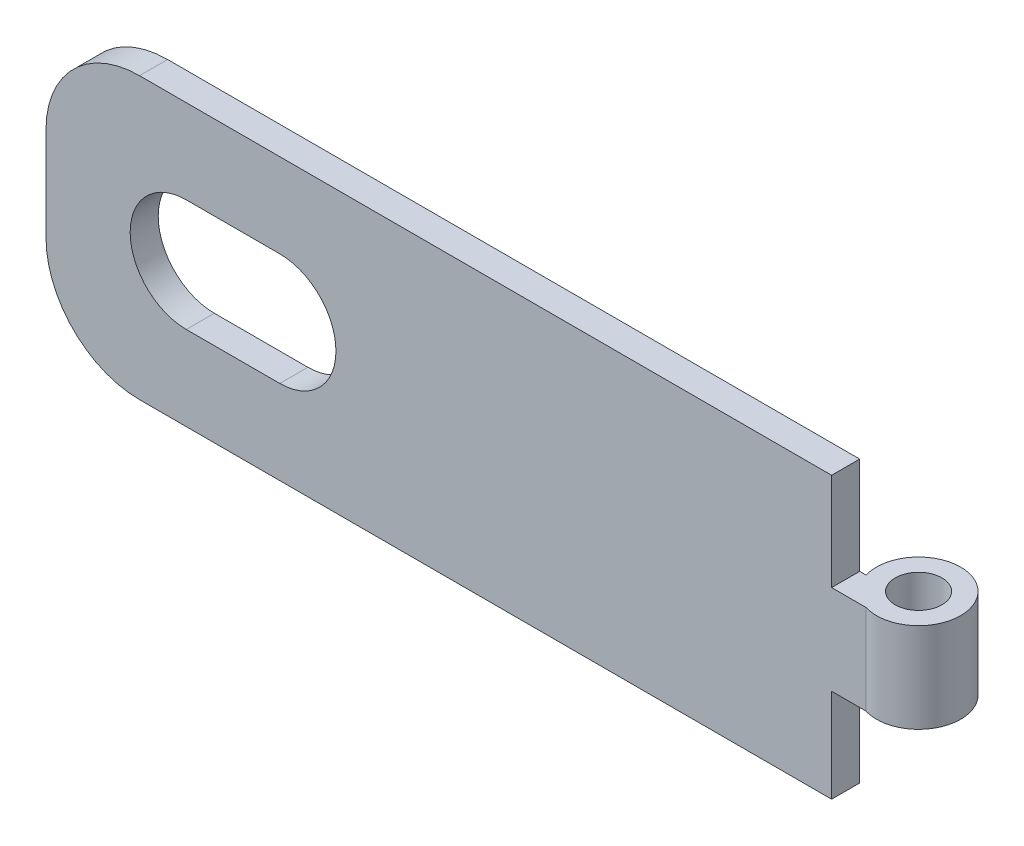
from build123d import *

# Parameters (mm, degrees)
SKETCH_1_W               = 88
SKETCH_1_H               = 3
EXTRUDE_1_DEPTH          = 30
SKETCH_2_R               = 4.5
EXTRUDE_1_2_DEPTH        = 30
SKETCH_3_R               = 2.5
CUT_EXTRUDE_1_DEPTH      = 31
SKETCH_4_W               = 11
SKETCH_4_H               = 10.4
SKETCH_4_H_2             = 10
CUT_EXTRUDE_2_DEPTH      = 4.2
CUT_EXTRUDE_2_DEPTH_BACK = 6.8
CUT_EXTRUDE_3_DEPTH      = 9.8


with BuildPart() as part:
    # Эскиз1 → Extrude 1 (new body)
    with BuildSketch(Plane(origin=(0, 0, 0), x_dir=(1, 0, 0), z_dir=(0, 1, 0))):
        with Locations((44, -1.5)):
            Rectangle(SKETCH_1_W, SKETCH_1_H)
    extrude(amount=EXTRUDE_1_DEPTH)

    # Эскиз2 → Extrude 1 2 (add)
    with BuildSketch(Plane(origin=(0, 0, 0), x_dir=(1, 0, 0), z_dir=(0, 1, 0))):
        with Locations((89, 1.3)):
            Circle(SKETCH_2_R)
    extrude(amount=EXTRUDE_1_2_DEPTH)

    # Эскиз3 → Вырез-Вытянуть1 (cut, through all)
    with BuildSketch(Plane(origin=(0, 0, 0), x_dir=(1, 0, 0), z_dir=(0, 1, 0))):
        with Locations((89, 1.3)):
            Circle(SKETCH_3_R)
    extrude(amount=CUT_EXTRUDE_1_DEPTH, mode=Mode.SUBTRACT)

    # Эскиз4 → Вырез-Вытянуть2 (cut, two sides)
    with BuildSketch(Plane.XY) as cut_extrude_2_sk:
        with Locations((89.5, 24.8)):
            Rectangle(SKETCH_4_W, SKETCH_4_H)
        with Locations((89.5, 5)):
            Rectangle(SKETCH_4_W, SKETCH_4_H_2)
    extrude(amount=CUT_EXTRUDE_2_DEPTH, mode=Mode.SUBTRACT)
    extrude(cut_extrude_2_sk.sketch, amount=-CUT_EXTRUDE_2_DEPTH_BACK, mode=Mode.SUBTRACT)

    # Эскиз5 → Вырез-Вытянуть3 (cut, through all)
    with BuildSketch(Plane.XY.offset(3)):
        with BuildLine():
            Line((15, 21), (25, 21))
            ThreePointArc((25, 21), (31, 15), (25, 9))
            Line((25, 9), (15, 9))
            ThreePointArc((15, 9), (9, 15), (15, 21))
        make_face()
        with BuildLine():
            Line((10, 30), (0, 30))
            Line((0, 30), (0, 20))
            ThreePointArc((0, 20), (2.928932188, 27.071067812), (10, 30))
        make_face()
        with BuildLine():
            Line((0, 10), (0, 0))
            Line((0, 0), (10, 0))
            ThreePointArc((10, 0), (2.928932188, 2.928932188), (0, 10))
        make_face()
    extrude(amount=-CUT_EXTRUDE_3_DEPTH, mode=Mode.SUBTRACT)


solid = part.part
